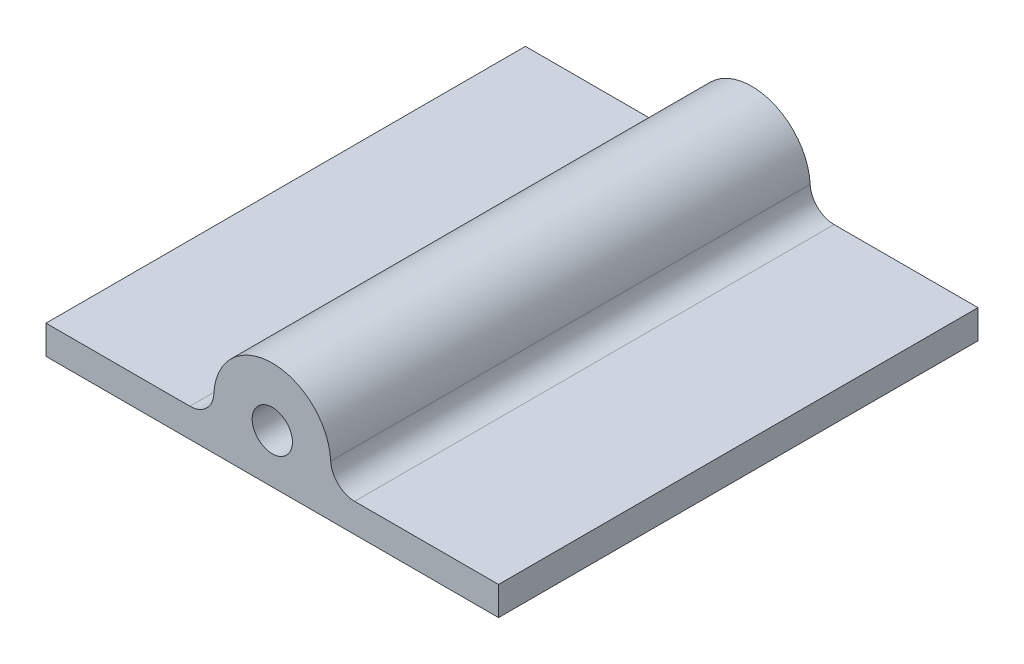
from build123d import *

# Parameters (mm, degrees)
SKETCH2_R           = 4.2
BOSS_EXTRUDE1_DEPTH = 100
FILLET1_R           = 5


with BuildPart() as part:
    # Sketch2 → Boss-Extrude1 (new body)
    with BuildSketch(Plane.XY):
        with BuildLine():
            Line((15.440624277, -4.881535018), (15.440624277, -0.681535018))
            ThreePointArc((15.440624277, -0.681535018), (3.240624277, 11.518464982), (-8.959375723, -0.681535018))
            Line((-8.959375723, -0.681535018), (-8.959375723, -4.881535018))
            Line((-8.959375723, -4.881535018), (-43.959375723, -4.881535018))
            Line((-43.959375723, -4.881535018), (-43.959375723, -10.881535018))
            Line((-43.959375723, -10.881535018), (50.440624277, -10.881535018))
            Line((50.440624277, -10.881535018), (50.440624277, -4.881535018))
            Line((50.440624277, -4.881535018), (15.440624277, -4.881535018))
        make_face()
        with Locations((3.240624277, -0.681535018)):
            Circle(SKETCH2_R, mode=Mode.SUBTRACT)
    extrude(amount=BOSS_EXTRUDE1_DEPTH)

    # Fillet1
    fillet1_edges = [part.edges().sort_by_distance(p)[0] for p in [
        (-8.959375723, -4.881535018, 50),
        (15.440624277, -4.881535018, 50),
    ]]
    fillet(fillet1_edges, radius=FILLET1_R)


solid = part.part
